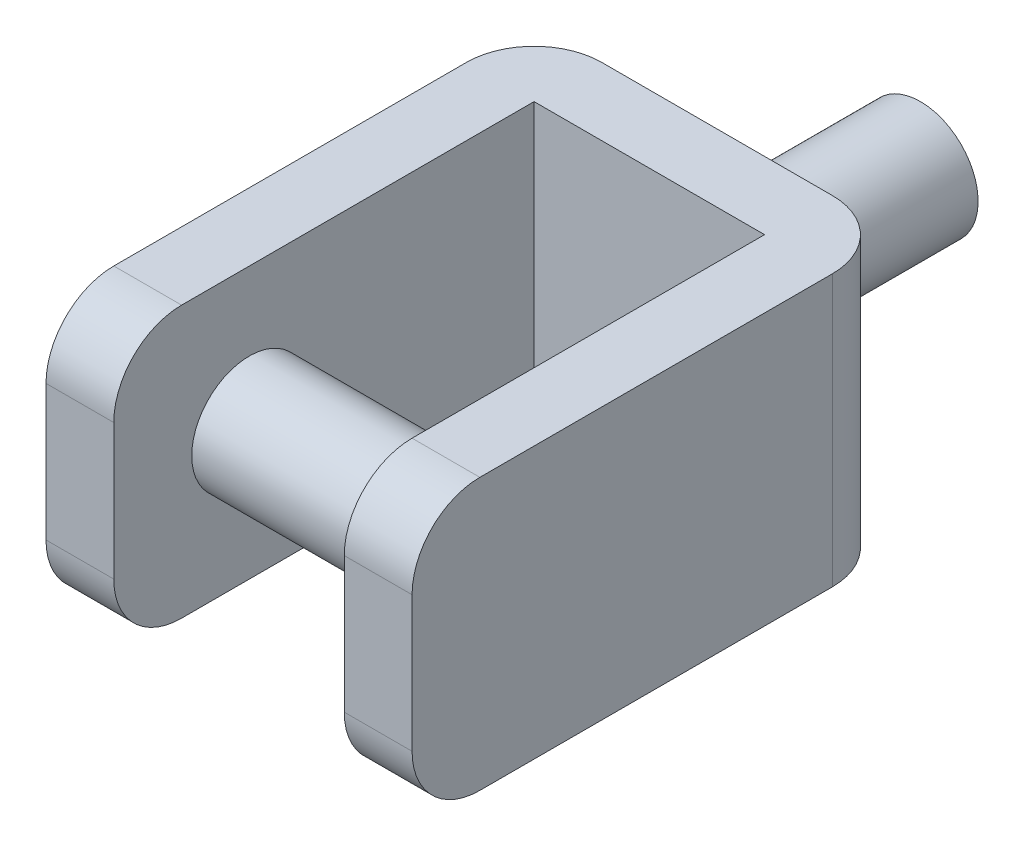
from build123d import *

# Parameters (mm, degrees)
BOSS_EXTRUDE1_DEPTH = 101.6
BOSS_EXTRUDE2_REACH = 113.76
SKETCH3_R           = 21.59
SKETCH4_R           = 21.59
BOSS_EXTRUDE3_DEPTH = 76.2
FILLET1_R           = 25.4
FILLET2_R           = 25.4
FILLET4_R           = 25.4
FILLET5_R           = 25.4


with BuildPart() as part:
    # Sketch1 → Boss-Extrude1 (new body)
    with BuildSketch(Plane(origin=(0, 0, 0), x_dir=(1, 0, 0), z_dir=(0, 1, 0))):
        Polygon((-37.133661193, -33.44672), (-62.533661193, -33.44672), (-62.533661193, 149.43328), (74.626338807, 149.43328), (74.626338807, -33.44672), (49.226338807, -33.44672), (49.226338807, 124.03328), (-37.133661193, 124.03328), align=None)
    extrude(amount=BOSS_EXTRUDE1_DEPTH)

    # Sketch3 → Boss-Extrude2 (add, up to next)
    with BuildSketch(Plane(origin=(-37.133661193, 0, 0), x_dir=(0, 0, -1), z_dir=(1, 0, 0)), mode=Mode.PRIVATE) as boss_extrude2_sk1:
        with Locations((17.35328, 50.8)):
            Circle(SKETCH3_R)
    boss_extrude2_tool1 = extrude(boss_extrude2_sk1.sketch, amount=BOSS_EXTRUDE2_REACH, mode=Mode.PRIVATE) - part.part
    add(boss_extrude2_tool1.solids().sort_by_distance((-37.133661, 50.8, -17.35328))[0])

    # Sketch4 → Boss-Extrude3 (add)
    with BuildSketch(Plane(origin=(0, 0, -149.43328), x_dir=(-1, 0, 0), z_dir=(0, 0, -1))):
        with Locations((-6.046338807, 50.8)):
            Circle(SKETCH4_R)
    extrude(amount=BOSS_EXTRUDE3_DEPTH)

    # Fillet1
    fillet1_edges = [part.edges().sort_by_distance(p)[0] for p in [
        (-49.833661193, 101.6, 33.44672),
        (-49.833661193, 0, 33.44672),
    ]]
    fillet(fillet1_edges, radius=FILLET1_R)

    # Fillet2
    fillet2_edges = [part.edges().sort_by_distance(p)[0] for p in [
        (-62.533661193, 50.8, -149.43328),
    ]]
    fillet(fillet2_edges, radius=FILLET2_R)

    # Fillet4
    fillet4_edges = [part.edges().sort_by_distance(p)[0] for p in [
        (61.926338807, 0, 33.44672),
        (61.926338807, 101.6, 33.44672),
    ]]
    fillet(fillet4_edges, radius=FILLET4_R)

    # Fillet5
    fillet5_edges = [part.edges().sort_by_distance(p)[0] for p in [
        (74.626338807, 50.8, -149.43328),
    ]]
    fillet(fillet5_edges, radius=FILLET5_R)


solid = part.part
